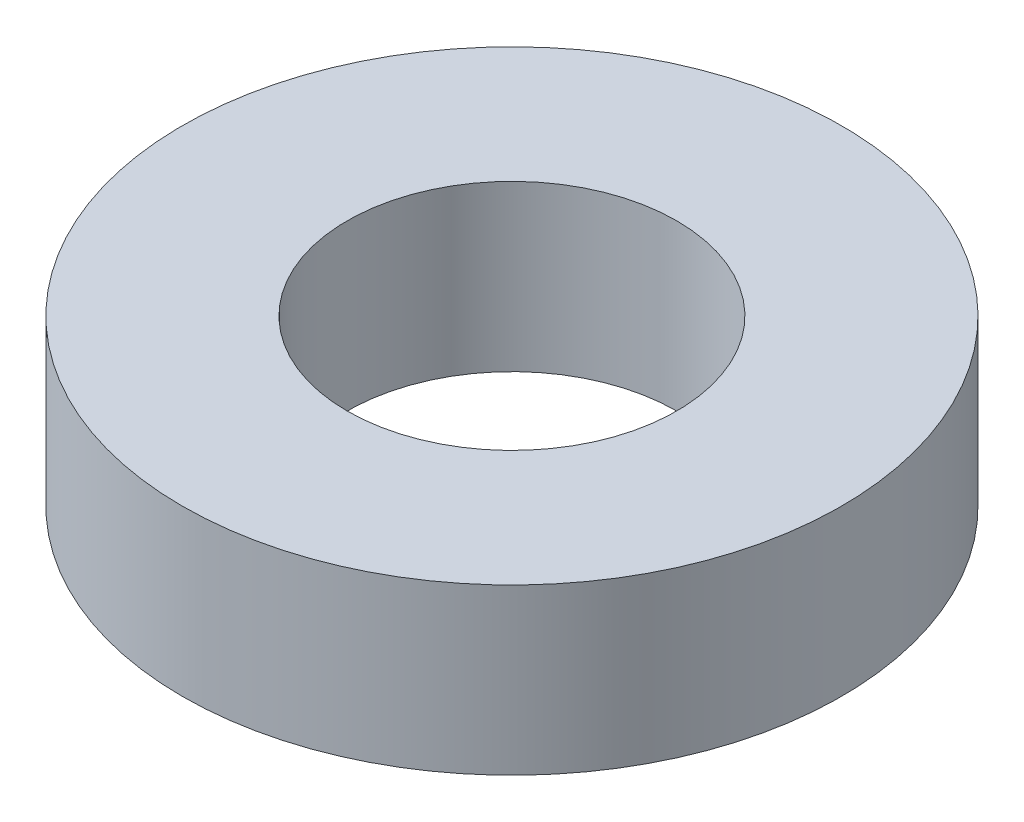
from build123d import *

# Parameters (mm, degrees)
SKETCH1_R           = 4
SKETCH1_R_2         = 2
BOSS_EXTRUDE1_DEPTH = 2


with BuildPart() as part:
    # Sketch1 → Boss-Extrude1 (new body)
    with BuildSketch(Plane(origin=(0, 0, 0), x_dir=(1, 0, 0), z_dir=(0, 1, 0))):
        Circle(SKETCH1_R)
        Circle(SKETCH1_R_2, mode=Mode.SUBTRACT)
    extrude(amount=BOSS_EXTRUDE1_DEPTH)


solid = part.part
